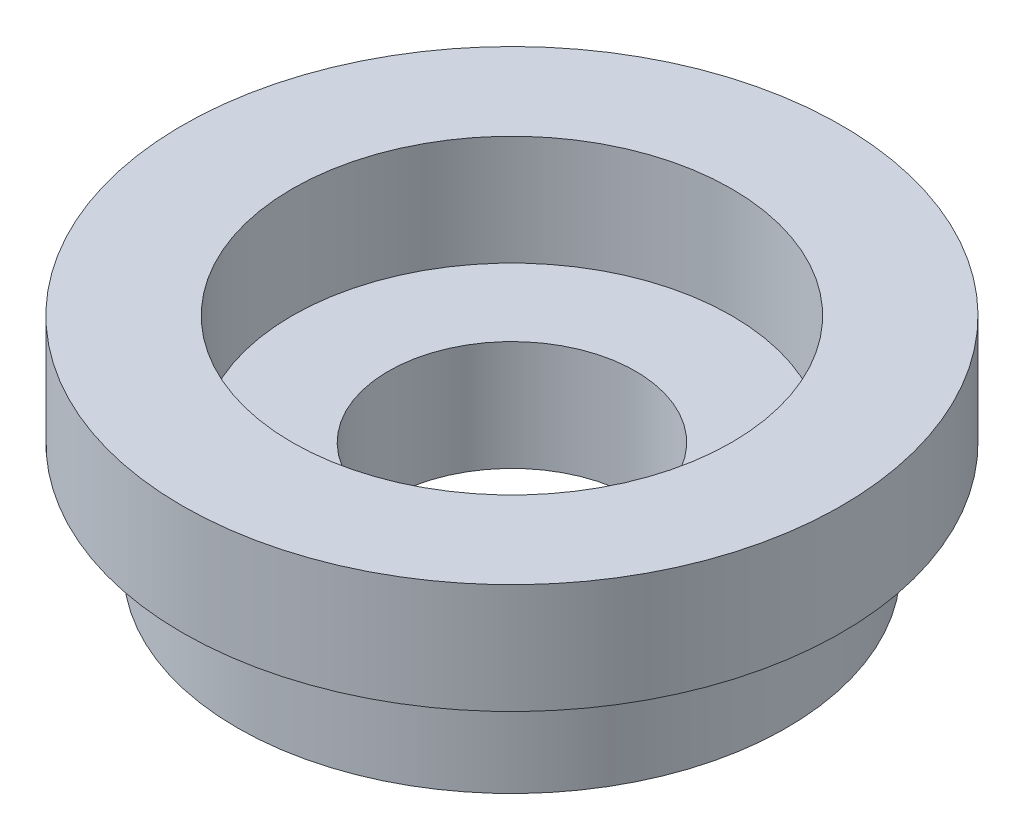
from build123d import *

# Parameters (mm, degrees)
SKETCH_1_R                   = 5
EXTRUDE_1_DEPTH              = 2
SKETCH_2_R                   = 6
EXTRUDE_2_DEPTH              = 2
HOLE_WIZARD_M4_1_D           = 4.5
HOLE_WIZARD_M4_1_CBORE_D     = 8
HOLE_WIZARD_M4_1_CBORE_DEPTH = 2


with BuildPart() as part:
    # 스케치1 → 보스-돌출1 (new body)
    with BuildSketch(Plane(origin=(0, 0, 0), x_dir=(1, 0, 0), z_dir=(0, 1, 0))):
        Circle(SKETCH_1_R)
    extrude(amount=EXTRUDE_1_DEPTH)

    # 스케치2 → 보스-돌출2 (add)
    with BuildSketch(Plane(origin=(0, 2, 0), x_dir=(1, 0, 0), z_dir=(0, 1, 0))):
        Circle(SKETCH_2_R)
    extrude(amount=EXTRUDE_2_DEPTH)

    # M4 육각 소켓 머리 캡 나사용 카운터보어1 (through all)
    with Locations(Plane(origin=(0, 4, 0), x_dir=(1, 0, 0), z_dir=(0, 1, 0))):
        with Locations((0, 0)):
            CounterBoreHole(HOLE_WIZARD_M4_1_D / 2, HOLE_WIZARD_M4_1_CBORE_D / 2, HOLE_WIZARD_M4_1_CBORE_DEPTH)


solid = part.part
